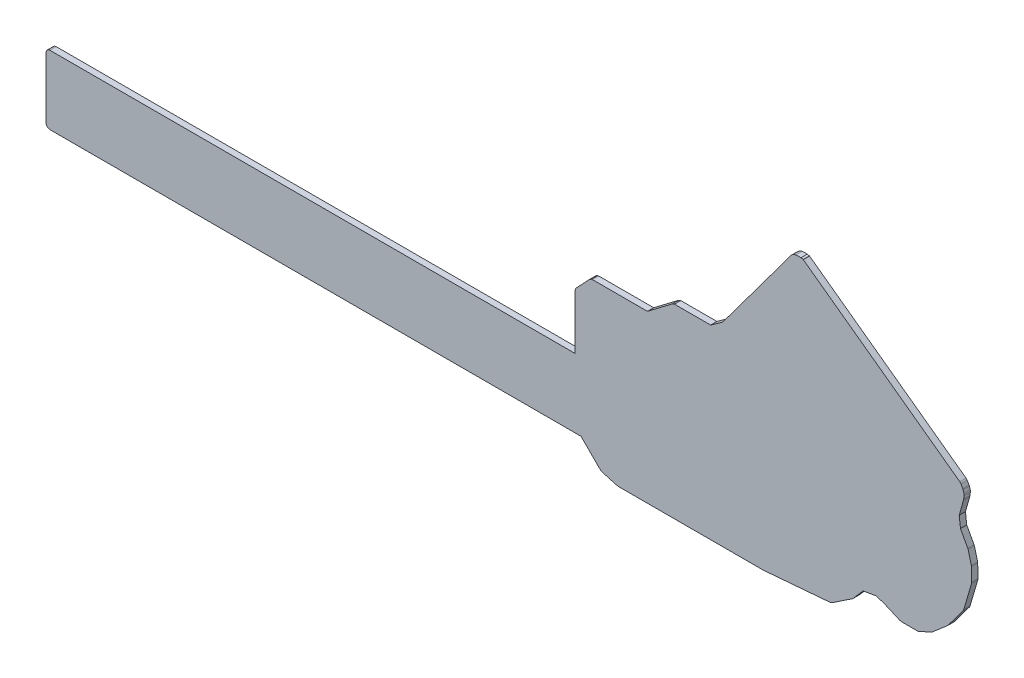
from build123d import *

# Parameters (mm, degrees)
BOSS_EXTRUDE1_DEPTH   = 0.2
BOSS_EXTRUDE1_2_DEPTH = 0.2


with BuildPart() as part:
    # Model → Boss-Extrude1 (new body)
    with BuildSketch(Plane.XY):
        Polygon((-0.719000633, 4.476263641), (-0.709000633, 4.470263641), (4.284999367, 0.831263641), (4.318999367, 0.792263641), (4.379999367, 0.686263641), (4.389999367, 0.663263641), (4.416999367, 0.582263641), (4.422999367, 0.527263641), (4.406999367, 0.404263641), (4.403999367, 0.386263641), (4.265999367, -0.104736359), (4.305999367, -0.454736359), (4.538999367, -0.881736359), (4.549999367, -0.909736359), (4.651999367, -1.300736359), (4.655999367, -1.329736359), (4.665999367, -1.755736359), (4.660999367, -1.792736359), (4.411999367, -2.642736359), (4.392999367, -2.682736359), (3.913999367, -3.323736359), (3.895999367, -3.343736359), (3.418999367, -3.753736359), (3.390999367, -3.771736359), (2.990999367, -3.962736359), (2.937999367, -3.974736359), (2.421999367, -3.974736359), (2.371999367, -3.964736359), (1.865999367, -3.744736359), (1.605999367, -3.664736359), (1.195999367, -3.734736359), (0.876999367, -4.101736359), (0.851999367, -4.123736359), (0.202999367, -4.556736359), (0.143999367, -4.577736359), (-1.991000633, -4.754736359), (-1.997000633, -4.754736359), (-6.627000633, -4.754736359), (-6.660000633, -4.749736359), (-7.143000633, -4.613736359), (-7.197000633, -4.581736359), (-7.814000633, -3.964736359), (-7.999000633, -3.964736359), (-8.005000633, -3.962736359), (-24.783000633, -3.962736359), (-24.850000633, -3.942736359), (-24.896000633, -3.890736359), (-24.907000633, -3.838736359), (-24.907000633, -1.889736359), (-24.888000633, -1.822736359), (-24.835000633, -1.776736359), (-24.783000633, -1.765736359), (-8.005000633, -1.765736359), (-8.004000633, -1.764736359), (-8.004000633, -0.023736359), (-7.984000633, 0.043263641), (-7.970000633, 0.061263641), (-7.541000633, 0.516263641), (-7.480000633, 0.551263641), (-7.450000633, 0.555263641), (-5.694000633, 0.555263641), (-4.897000633, 1.160263641), (-4.832000633, 1.185263641), (-4.822000633, 1.185263641), (-3.674000633, 1.185263641), (-3.284000633, 1.465263641), (-1.099000633, 4.405263641), (-1.063000633, 4.438263641), (-1.011000633, 4.469263641), (-0.952000633, 4.486263641), (-0.787000633, 4.493263641), align=None)
    extrude(amount=BOSS_EXTRUDE1_DEPTH)


with BuildPart() as body_2:
    # Model → Boss-Extrude1 2 (new body)
    with BuildSketch(Plane.XY):
        Polygon((-12.208000633, 15.583263641), (-12.129000633, 15.567263641), (-12.085000633, 15.549263641), (-12.028000633, 15.511263641), (-11.994000633, 15.477263641), (-11.957000633, 15.420263641), (-11.938000633, 15.376263641), (-11.922000633, 15.297263641), (-11.920000633, 15.273263641), (-11.920000633, 14.001263641), (-11.922000633, 13.977263641), (-11.938000633, 13.898263641), (-11.957000633, 13.854263641), (-11.994000633, 13.797263641), (-12.028000633, 13.763263641), (-12.085000633, 13.725263641), (-12.129000633, 13.707263641), (-12.208000633, 13.691263641), (-12.232000633, 13.689263641), (-12.403000633, 13.689263641), (-12.518000633, 13.666263641), (-12.615000633, 13.601263641), (-12.680000633, 13.504263641), (-12.703000633, 13.389263641), (-12.703000633, 10.112263641), (-12.705000633, 10.088263641), (-12.721000633, 10.009263641), (-12.739000633, 9.964263641), (-12.777000633, 9.908263641), (-12.811000633, 9.874263641), (-12.868000633, 9.836263641), (-12.912000633, 9.818263641), (-12.991000633, 9.802263641), (-13.015000633, 9.800263641), (-14.285000633, 9.800263641), (-14.361000633, 9.784263641), (-14.426000633, 9.741263641), (-14.470000633, 9.676263641), (-14.485000633, 9.600263641), (-14.485000633, 9.081263641), (-14.487000633, 9.057263641), (-14.495000633, 9.017263641), (-14.514000633, 8.972263641), (-14.530000633, 8.948263641), (-14.564000633, 8.914263641), (-14.566000633, 8.913263641), (-14.632000633, 8.892263641), (-14.635000633, 8.892263641), (-18.652000633, 8.895263641), (-18.720000633, 8.914263641), (-18.755000633, 8.950263641), (-18.770000633, 8.972263641), (-18.789000633, 9.017263641), (-18.797000633, 9.057263641), (-18.799000633, 9.081263641), (-18.799000633, 9.600263641), (-18.815000633, 9.676263641), (-18.858000633, 9.741263641), (-18.923000633, 9.784263641), (-18.999000633, 9.800263641), (-19.007000633, 9.800263641), (-19.021000633, 9.804263641), (-21.430000633, 9.804263641), (-21.497000633, 9.823263641), (-21.543000633, 9.876263641), (-21.554000633, 9.928263641), (-21.554000633, 9.985263641), (-21.577000633, 10.100263641), (-21.642000633, 10.197263641), (-21.739000633, 10.262263641), (-21.854000633, 10.285263641), (-22.082000633, 10.285263641), (-22.106000633, 10.287263641), (-22.146000633, 10.296263641), (-22.191000633, 10.314263641), (-22.215000633, 10.330263641), (-22.249000633, 10.364263641), (-22.265000633, 10.388263641), (-22.284000633, 10.433263641), (-22.292000633, 10.473263641), (-22.294000633, 10.497263641), (-22.294000633, 12.473263641), (-22.292000633, 12.497263641), (-22.284000633, 12.537263641), (-22.265000633, 12.582263641), (-22.249000633, 12.606263641), (-22.215000633, 12.640263641), (-22.191000633, 12.656263641), (-22.146000633, 12.675263641), (-22.106000633, 12.683263641), (-22.082000633, 12.685263641), (-21.854000633, 12.685263641), (-21.739000633, 12.708263641), (-21.642000633, 12.773263641), (-21.577000633, 12.870263641), (-21.554000633, 12.985263641), (-21.554000633, 15.273263641), (-21.552000633, 15.297263641), (-21.536000633, 15.376263641), (-21.517000633, 15.420263641), (-21.480000633, 15.477263641), (-21.446000633, 15.511263641), (-21.389000633, 15.549263641), (-21.345000633, 15.567263641), (-21.266000633, 15.583263641), (-21.242000633, 15.585263641), (-12.232000633, 15.585263641), align=None)
    extrude(amount=BOSS_EXTRUDE1_2_DEPTH)


solid = part.part
